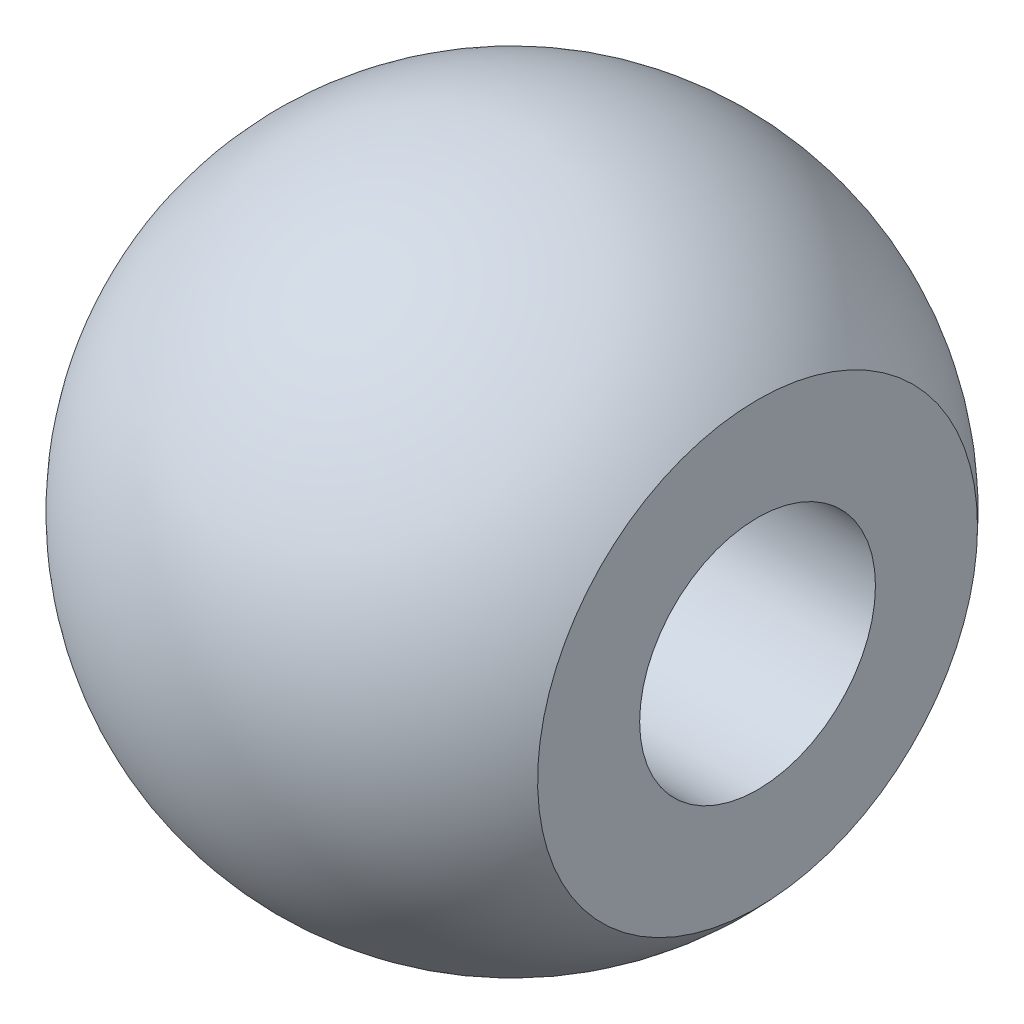
from build123d import *

# Parameters (mm, degrees)
F_1_4_20_TAPPED_HOLE1_D     = 5.1054
F_1_4_20_TAPPED_HOLE1_DEPTH = 8.89
F_1_4_20_TAPPED_HOLE1_TIP   = 1.533816902


with BuildPart() as part:
    # Sketch2 → Revolve1 (revolve)
    with BuildSketch(Plane.XY):
        with BuildLine():
            Line((-7.1374, 0), (5.316114418, 0))
            Line((5.316114418, 0), (5.316114418, 4.7625))
            ThreePointArc((5.316114418, 4.7625), (-2.549435595, 6.6665476), (-7.1374, 0))
        make_face()
    revolve(axis=Axis((0, 0, 0), (-1, 0, 0)))

    # 1/4-20 Tapped Hole1
    with Locations(Plane(origin=(5.316114418, 0, 0), x_dir=(0, 0, -1), z_dir=(1, 0, 0))):
        with Locations((0, 0)):
            Hole(F_1_4_20_TAPPED_HOLE1_D / 2, depth=F_1_4_20_TAPPED_HOLE1_DEPTH)
            with Locations((0, 0, -(F_1_4_20_TAPPED_HOLE1_DEPTH + F_1_4_20_TAPPED_HOLE1_TIP / 2))):  # 118° drill point
                Cone(0, F_1_4_20_TAPPED_HOLE1_D / 2, F_1_4_20_TAPPED_HOLE1_TIP, mode=Mode.SUBTRACT)


solid = part.part
